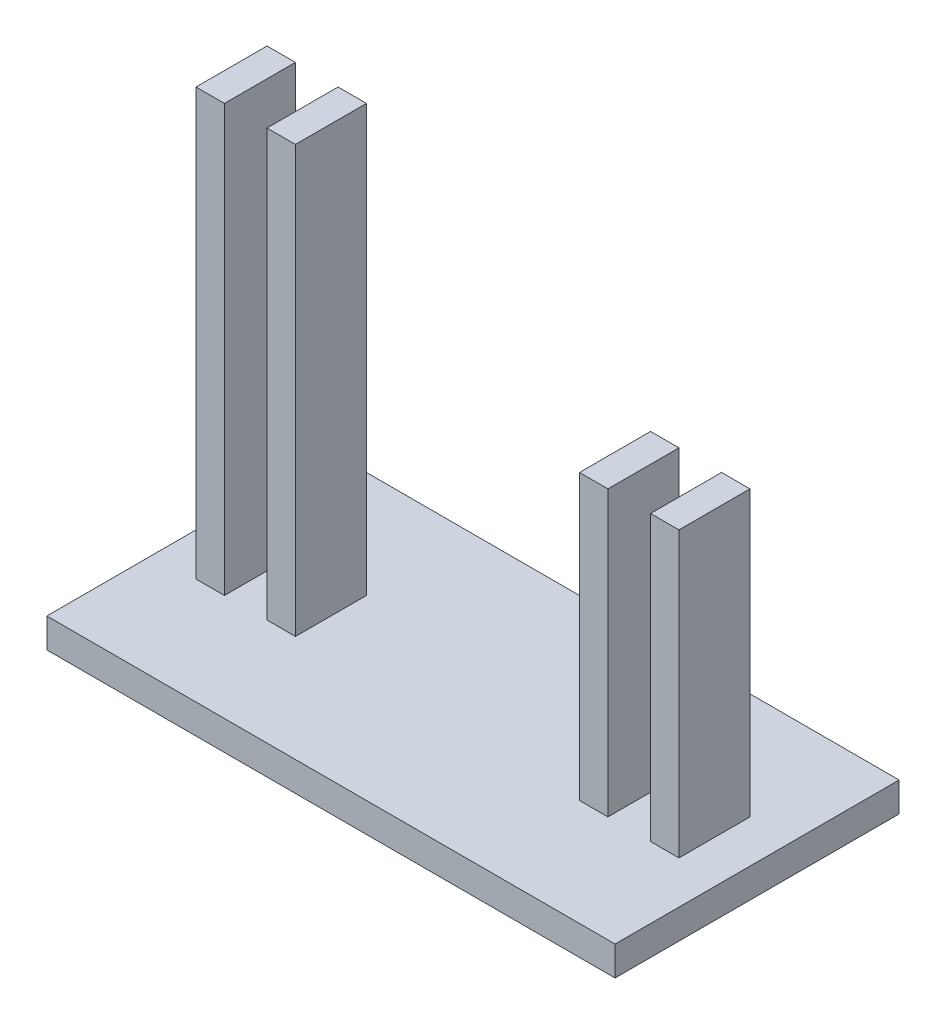
from build123d import *

# Parameters (mm, degrees)
SKETCH2_W           = 200
SKETCH2_H           = 100
BOSS_EXTRUDE1_DEPTH = 10.357742679
SKETCH4_W           = 10
SKETCH4_H           = 25
BOSS_EXTRUDE2_DEPTH = 150
SKETCH7_W           = 10
SKETCH7_H           = 25
BOSS_EXTRUDE3_DEPTH = 100


with BuildPart() as part:
    # Sketch2 → Boss-Extrude1 (new body)
    with BuildSketch(Plane(origin=(0, 0, 0), x_dir=(1, 0, 0), z_dir=(0, 1, 0))):
        Rectangle(SKETCH2_W, SKETCH2_H)
    extrude(amount=BOSS_EXTRUDE1_DEPTH)

    # Sketch4 → Boss-Extrude2 (add)
    with BuildSketch(Plane(origin=(0, 10.357742679, 0), x_dir=(1, 0, 0), z_dir=(0, 1, 0))):
        with Locations((-80, 0)):
            Rectangle(SKETCH4_W, SKETCH4_H)
        with Locations((-55, 0)):
            Rectangle(SKETCH4_W, SKETCH4_H)
    extrude(amount=BOSS_EXTRUDE2_DEPTH)

    # Sketch7 → Boss-Extrude3 (add)
    with BuildSketch(Plane(origin=(0, 10.357742679, 0), x_dir=(1, 0, 0), z_dir=(0, 1, 0))):
        with Locations((80, 0)):
            Rectangle(SKETCH7_W, SKETCH7_H)
        with Locations((55, 0)):
            Rectangle(SKETCH7_W, SKETCH7_H)
    extrude(amount=BOSS_EXTRUDE3_DEPTH)


solid = part.part
